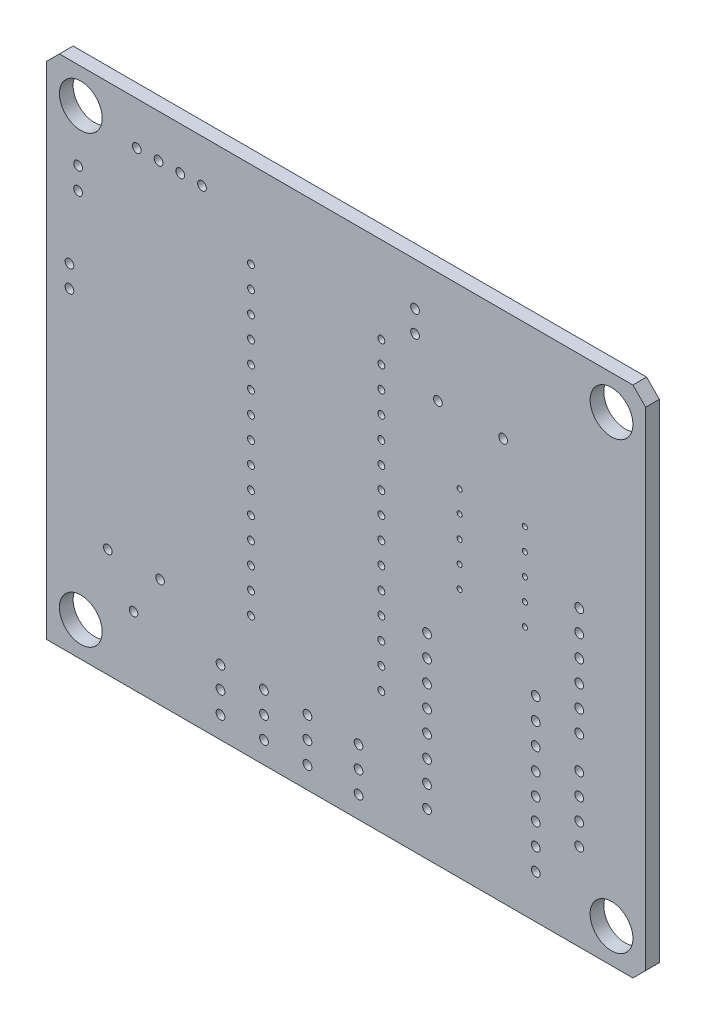
from build123d import *

# Parameters (mm, degrees)
BOARD_OUTLINE_1_DEPTH = 1.6
SKETCH2_R             = 2.500000067
BOARD_OUTLINE_2_DEPTH = 2.6
SKETCH3_R             = 2.50000052
BOARD_OUTLINE_3_DEPTH = 2.6
SKETCH4_R             = 2.500000067
BOARD_OUTLINE_4_DEPTH = 2.6
SKETCH5_R             = 2.500000039
BOARD_OUTLINE_5_DEPTH = 2.6
SKETCH6_R             = 0.51
SKETCH6_R_2           = 0.3
SKETCH6_R_3           = 0.5
SKETCH6_R_4           = 0.405
PTH_DEPTH             = 2.6


with BuildPart() as part:
    # Sketch1 → Board_Outline 1 (new body)
    with BuildSketch(Plane.XY):
        Polygon((0, 0), (68.5, 0), (70, 1.5), (70, 58.5), (68.5, 60), (1.5, 60), (0, 58.5), align=None)
        Polygon((1.5, 4), (1.585185, 3.352952), (1.834936, 2.75), (2.232233, 2.232233), (2.75, 1.834936), (3.352952, 1.585185), (4, 1.5), (4.647048, 1.585185), (5.25, 1.834936), (5.767767, 2.232233), (6.165064, 2.75), (6.414815, 3.352952), (6.5, 4), (6.478612, 4.326315), (6.414815, 4.647048), (6.165064, 5.25), (5.767767, 5.767767), (5.25, 6.165064), (4.647048, 6.414815), (4, 6.5), (3.352952, 6.414815), (2.75, 6.165064), (2.232233, 5.767767), (1.834936, 5.25), (1.585185, 4.647048), align=None, mode=Mode.SUBTRACT)
        Polygon((1.5, 56), (1.585185, 55.352952), (1.834936, 54.75), (2.232233, 54.232233), (2.75, 53.834936), (3.352952, 53.585185), (4, 53.5), (4.647048, 53.585185), (5.25, 53.834936), (5.767767, 54.232233), (6.165064, 54.75), (6.414815, 55.352952), (6.5, 56), (6.478612, 56.326315), (6.414815, 56.647048), (6.165064, 57.25), (5.767767, 57.767767), (5.25, 58.165064), (4.647048, 58.414815), (4, 58.5), (3.352952, 58.414815), (2.75, 58.165064), (2.232233, 57.767767), (1.834936, 57.25), (1.585185, 56.647048), align=None, mode=Mode.SUBTRACT)
        Polygon((63.5, 4), (63.585185, 3.352952), (63.834936, 2.75), (64.232233, 2.232233), (64.75, 1.834936), (65.352952, 1.585185), (66, 1.5), (66.647048, 1.585185), (67.25, 1.834936), (67.767767, 2.232233), (68.165064, 2.75), (68.414815, 3.352952), (68.5, 4), (68.478612, 4.326315), (68.414815, 4.647048), (68.165064, 5.25), (67.767767, 5.767767), (67.25, 6.165064), (66.647048, 6.414815), (66, 6.5), (65.352952, 6.414815), (64.75, 6.165064), (64.232233, 5.767767), (63.834936, 5.25), (63.585185, 4.647048), align=None, mode=Mode.SUBTRACT)
        Polygon((63.5, 56), (63.585185, 55.352952), (63.834936, 54.75), (64.232233, 54.232233), (64.75, 53.834936), (65.352952, 53.585185), (66, 53.5), (66.647048, 53.585185), (67.25, 53.834936), (67.767767, 54.232233), (68.165064, 54.75), (68.414815, 55.352952), (68.5, 56), (68.478612, 56.326315), (68.414815, 56.647048), (68.165064, 57.25), (67.767767, 57.767767), (67.25, 58.165064), (66.647048, 58.414815), (66, 58.5), (65.352952, 58.414815), (64.75, 58.165064), (64.232233, 57.767767), (63.834936, 57.25), (63.585185, 56.647048), align=None, mode=Mode.SUBTRACT)
    extrude(amount=BOARD_OUTLINE_1_DEPTH)

    # Sketch2 → Board_Outline 2 (cut, through all)
    with BuildSketch(Plane.XY):
        with Locations((4, 56)):
            Circle(SKETCH2_R)
    extrude(amount=BOARD_OUTLINE_2_DEPTH, mode=Mode.SUBTRACT)

    # Sketch3 → Board_Outline 3 (cut, through all)
    with BuildSketch(Plane.XY):
        with Locations((66, 56)):
            Circle(SKETCH3_R)
    extrude(amount=BOARD_OUTLINE_3_DEPTH, mode=Mode.SUBTRACT)

    # Sketch4 → Board_Outline 4 (cut, through all)
    with BuildSketch(Plane.XY):
        with Locations((66, 4)):
            Circle(SKETCH4_R)
    extrude(amount=BOARD_OUTLINE_4_DEPTH, mode=Mode.SUBTRACT)

    # Sketch5 → Board_Outline 5 (cut, through all)
    with BuildSketch(Plane.XY):
        with Locations((4.000000039, 4)):
            Circle(SKETCH5_R)
    extrude(amount=BOARD_OUTLINE_5_DEPTH, mode=Mode.SUBTRACT)

    # Sketch6 → PTH (cut, through all)
    with BuildSketch(Plane.XY):
        with Locations((53.34, 46.99)):
            Circle(SKETCH6_R)
        with Locations((45.72, 46.99)):
            Circle(SKETCH6_R)
        with Locations((30.48, 7.62)):
            Circle(SKETCH6_R)
        with Locations((30.48, 5.08)):
            Circle(SKETCH6_R)
        with Locations((30.48, 2.54)):
            Circle(SKETCH6_R)
        with Locations((25.4, 7.62)):
            Circle(SKETCH6_R)
        with Locations((25.4, 5.08)):
            Circle(SKETCH6_R)
        with Locations((25.4, 2.54)):
            Circle(SKETCH6_R)
        with Locations((20.32, 7.62)):
            Circle(SKETCH6_R)
        with Locations((20.32, 5.08)):
            Circle(SKETCH6_R)
        with Locations((20.32, 2.54)):
            Circle(SKETCH6_R)
        with Locations((48.26, 34.29)):
            Circle(SKETCH6_R_2)
        with Locations((48.26, 39.37)):
            Circle(SKETCH6_R_2)
        with Locations((55.88, 39.37)):
            Circle(SKETCH6_R_2)
        with Locations((55.88, 31.75)):
            Circle(SKETCH6_R_2)
        with Locations((55.88, 34.29)):
            Circle(SKETCH6_R_2)
        with Locations((48.26, 31.75)):
            Circle(SKETCH6_R_2)
        with Locations((48.26, 29.21)):
            Circle(SKETCH6_R_2)
        with Locations((48.26, 36.83)):
            Circle(SKETCH6_R_2)
        with Locations((55.88, 36.83)):
            Circle(SKETCH6_R_2)
        with Locations((55.88, 29.21)):
            Circle(SKETCH6_R_2)
        with Locations((44.45, 22.86)):
            Circle(SKETCH6_R)
        with Locations((44.45, 20.32)):
            Circle(SKETCH6_R)
        with Locations((44.45, 17.78)):
            Circle(SKETCH6_R)
        with Locations((44.45, 15.24)):
            Circle(SKETCH6_R)
        with Locations((44.45, 12.7)):
            Circle(SKETCH6_R)
        with Locations((44.45, 10.16)):
            Circle(SKETCH6_R)
        with Locations((44.45, 7.62)):
            Circle(SKETCH6_R)
        with Locations((44.45, 5.08)):
            Circle(SKETCH6_R)
        with Locations((57.15, 5.08)):
            Circle(SKETCH6_R)
        with Locations((57.15, 7.62)):
            Circle(SKETCH6_R)
        with Locations((57.15, 10.16)):
            Circle(SKETCH6_R)
        with Locations((57.15, 12.7)):
            Circle(SKETCH6_R)
        with Locations((57.15, 15.24)):
            Circle(SKETCH6_R)
        with Locations((57.15, 17.78)):
            Circle(SKETCH6_R)
        with Locations((57.15, 20.32)):
            Circle(SKETCH6_R)
        with Locations((57.15, 22.86)):
            Circle(SKETCH6_R)
        with Locations((43.05, 52.45)):
            Circle(SKETCH6_R)
        with Locations((43.05, 54.99)):
            Circle(SKETCH6_R)
        with Locations((62.23, 21.59)):
            Circle(SKETCH6_R)
        with Locations((62.23, 24.13)):
            Circle(SKETCH6_R)
        with Locations((62.23, 26.67)):
            Circle(SKETCH6_R)
        with Locations((62.23, 29.21)):
            Circle(SKETCH6_R)
        with Locations((62.23, 31.75)):
            Circle(SKETCH6_R)
        with Locations((62.23, 34.29)):
            Circle(SKETCH6_R)
        with Locations((36.45, 2.54)):
            Circle(SKETCH6_R)
        with Locations((36.45, 5.08)):
            Circle(SKETCH6_R)
        with Locations((36.45, 7.62)):
            Circle(SKETCH6_R)
        with Locations((13.26, 12.7)):
            Circle(SKETCH6_R_3)
        with Locations((10.16, 7.9)):
            Circle(SKETCH6_R_3)
        with Locations((7.16, 12.7)):
            Circle(SKETCH6_R_3)
        with Locations((2.67, 36.83)):
            Circle(SKETCH6_R)
        with Locations((2.67, 39.37)):
            Circle(SKETCH6_R)
        with Locations((3.683, 49.784)):
            Circle(SKETCH6_R)
        with Locations((3.683, 47.244)):
            Circle(SKETCH6_R)
        with Locations((62.23, 17.78)):
            Circle(SKETCH6_R)
        with Locations((62.23, 15.24)):
            Circle(SKETCH6_R)
        with Locations((62.23, 12.7)):
            Circle(SKETCH6_R)
        with Locations((62.23, 10.16)):
            Circle(SKETCH6_R)
        with Locations((39.11, 14.35)):
            Circle(SKETCH6_R_4)
        with Locations((39.11, 16.89)):
            Circle(SKETCH6_R_4)
        with Locations((39.11, 19.43)):
            Circle(SKETCH6_R_4)
        with Locations((39.11, 21.97)):
            Circle(SKETCH6_R_4)
        with Locations((39.11, 24.51)):
            Circle(SKETCH6_R_4)
        with Locations((39.11, 27.05)):
            Circle(SKETCH6_R_4)
        with Locations((39.11, 29.59)):
            Circle(SKETCH6_R_4)
        with Locations((39.11, 32.13)):
            Circle(SKETCH6_R_4)
        with Locations((39.11, 34.67)):
            Circle(SKETCH6_R_4)
        with Locations((39.11, 37.21)):
            Circle(SKETCH6_R_4)
        with Locations((39.11, 39.75)):
            Circle(SKETCH6_R_4)
        with Locations((39.11, 42.29)):
            Circle(SKETCH6_R_4)
        with Locations((39.11, 44.83)):
            Circle(SKETCH6_R_4)
        with Locations((39.11, 47.37)):
            Circle(SKETCH6_R_4)
        with Locations((39.11, 49.91)):
            Circle(SKETCH6_R_4)
        with Locations((23.88, 49.91)):
            Circle(SKETCH6_R_4)
        with Locations((23.88, 47.37)):
            Circle(SKETCH6_R_4)
        with Locations((23.88, 44.83)):
            Circle(SKETCH6_R_4)
        with Locations((23.88, 42.29)):
            Circle(SKETCH6_R_4)
        with Locations((23.88, 39.75)):
            Circle(SKETCH6_R_4)
        with Locations((23.88, 37.21)):
            Circle(SKETCH6_R_4)
        with Locations((23.88, 34.67)):
            Circle(SKETCH6_R_4)
        with Locations((23.88, 32.13)):
            Circle(SKETCH6_R_4)
        with Locations((23.88, 29.59)):
            Circle(SKETCH6_R_4)
        with Locations((23.88, 27.05)):
            Circle(SKETCH6_R_4)
        with Locations((23.88, 24.51)):
            Circle(SKETCH6_R_4)
        with Locations((23.88, 21.97)):
            Circle(SKETCH6_R_4)
        with Locations((23.88, 19.43)):
            Circle(SKETCH6_R_4)
        with Locations((23.88, 16.89)):
            Circle(SKETCH6_R_4)
        with Locations((23.88, 14.35)):
            Circle(SKETCH6_R_4)
        with Locations((10.541, 54.991)):
            Circle(SKETCH6_R)
        with Locations((13.081, 54.991)):
            Circle(SKETCH6_R)
        with Locations((15.621, 54.991)):
            Circle(SKETCH6_R)
        with Locations((18.161, 54.991)):
            Circle(SKETCH6_R)
    extrude(amount=PTH_DEPTH, mode=Mode.SUBTRACT)


solid = part.part
